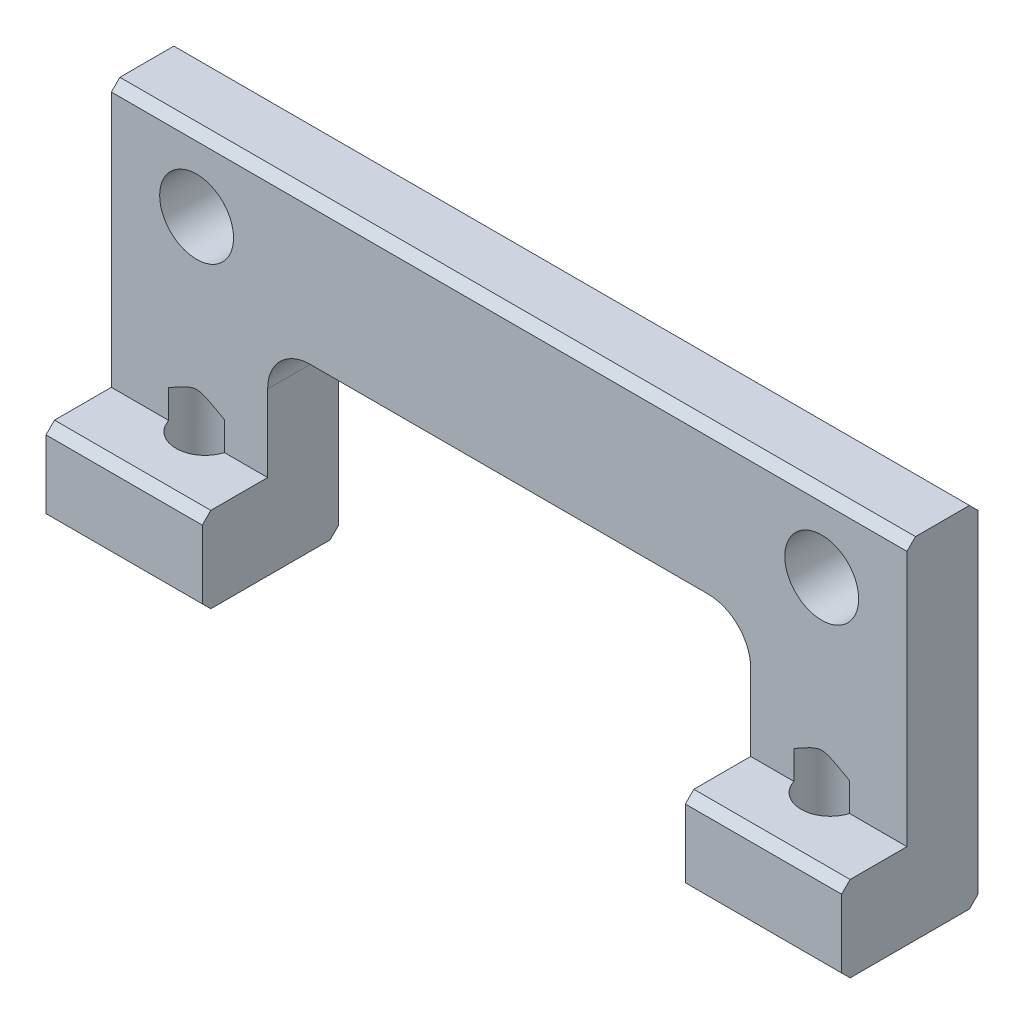
from build123d import *

# Parameters (mm, degrees)
SKETCH1_W                 = 5.5
SKETCH1_H                 = 12.3
BOSS_EXTRUDE1_DEPTH       = 4.8
SKETCH2_W                 = 2.3
SKETCH2_H                 = 9.3
CUT_EXTRUDE1_DEPTH        = 6.5
SKETCH3_W                 = 2.5
SKETCH3_H                 = 5.1
BOSS_EXTRUDE2_DEPTH       = 22.5
SKETCH4_W                 = 5.5
SKETCH4_H                 = 2.5
BOSS_EXTRUDE3_DEPTH       = 7.2
SKETCH5_W                 = 5.5
SKETCH5_H                 = 3
BOSS_EXTRUDE4_DEPTH       = 2.3
F_2_CLEARANCE_HOLE1_D     = 2.6
F_2_CLEARANCE_HOLE1_DEPTH = 4.8
F_1_CLEARANCE_HOLE1_D     = 2.05
F_1_CLEARANCE_HOLE1_DEPTH = 4
F_1_CLEARANCE_HOLE1_TIP   = 0.615882135
CHAMFER1_SIZE             = 0.3
CHAMFER2_SIZE             = 0.2
FILLET1_R                 = 1.5


with BuildPart() as part:
    # Sketch1 → Boss-Extrude1 (new body)
    with BuildSketch(Plane(origin=(0, 0, -2.5), x_dir=(-1, 0, 0), z_dir=(0, 0, -1))):
        with Locations((-11.25, 6.15)):
            Rectangle(SKETCH1_W, SKETCH1_H)
    extrude(amount=-BOSS_EXTRUDE1_DEPTH)

    # Sketch2 → Cut-Extrude1 (cut, through all)
    with BuildSketch(Plane.ZY.offset(-8.5)):
        with Locations((1.15, 7.65)):
            Rectangle(SKETCH2_W, SKETCH2_H)
    extrude(amount=-CUT_EXTRUDE1_DEPTH, mode=Mode.SUBTRACT)

    # Sketch3 → Boss-Extrude2 (add)
    with BuildSketch(Plane.ZY.offset(-8.5)):
        with Locations((-1.25, 9.75)):
            Rectangle(SKETCH3_W, SKETCH3_H)
    extrude(amount=BOSS_EXTRUDE2_DEPTH)

    # Sketch4 → Boss-Extrude3 (add)
    with BuildSketch(Plane.XZ.offset(-7.2)):
        with Locations((-11.25, -1.25)):
            Rectangle(SKETCH4_W, SKETCH4_H)
    extrude(amount=BOSS_EXTRUDE3_DEPTH)

    # Sketch5 → Boss-Extrude4 (add)
    with BuildSketch(Plane.XY):
        with Locations((-11.25, 1.5)):
            Rectangle(SKETCH5_W, SKETCH5_H)
    extrude(amount=BOSS_EXTRUDE4_DEPTH)

    # #2 Clearance Hole1
    with Locations(Plane(origin=(0, 0, -2.5), x_dir=(-1, 0, 0), z_dir=(0, 0, -1))):
        with Locations((11, 9.7), (-11, 9.7)):
            Hole(F_2_CLEARANCE_HOLE1_D / 2, depth=F_2_CLEARANCE_HOLE1_DEPTH)

    # #1 Clearance Hole1
    with Locations(Plane(origin=(0, 0, 0), x_dir=(-1, 0, 0), z_dir=(0, -1, 0))):
        with Locations((-11, 0.3), (11, 0.3)):
            Hole(F_1_CLEARANCE_HOLE1_D / 2, depth=F_1_CLEARANCE_HOLE1_DEPTH)
            with Locations((0, 0, -(F_1_CLEARANCE_HOLE1_DEPTH + F_1_CLEARANCE_HOLE1_TIP / 2))):  # 118° drill point
                Cone(0, F_1_CLEARANCE_HOLE1_D / 2, F_1_CLEARANCE_HOLE1_TIP, mode=Mode.SUBTRACT)

    # Chamfer1
    chamfer1_edges = [part.edges().sort_by_distance(p)[0] for p in [
        (11.25, 3, 2.3),
        (0, 12.3, 0),
        (11.25, 0, 2.3),
        (-11.25, 0, -2.5),
        (0, 12.3, -2.5),
        (-11.25, 0, 2.3),
        (11.25, 0, -2.5),
        (-11.25, 3, 2.3),
        (9.7, 9.7, -2.5),
        (-12.025, 0, -0.3),
        (9.975, 0, -0.3),
    ]]
    chamfer(chamfer1_edges, length=CHAMFER1_SIZE)

    # Chamfer2
    chamfer2_edges = [part.edges().sort_by_distance(p)[0] for p in [
        (-12.3, 9.7, -2.5),
    ]]
    chamfer(chamfer2_edges, length=CHAMFER2_SIZE)

    # Fillet1
    fillet1_edges = [part.edges().sort_by_distance(p)[0] for p in [
        (8.5, 7.2, -1.25),
        (-8.5, 7.2, -1.25),
    ]]
    fillet(fillet1_edges, radius=FILLET1_R)


solid = part.part
